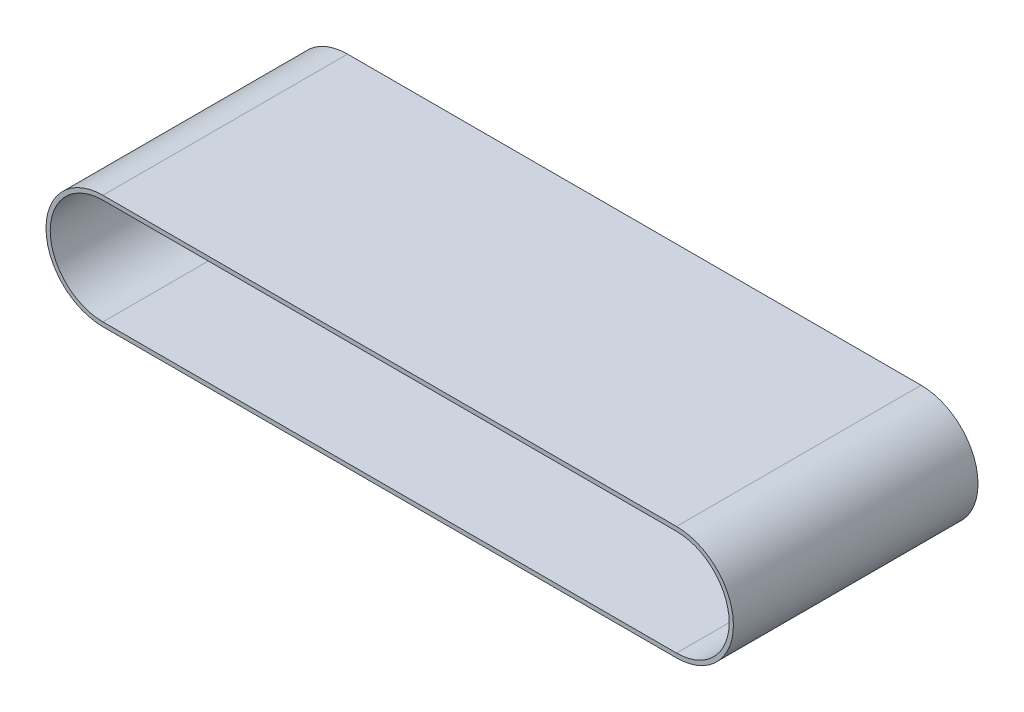
from build123d import *

# Parameters (mm, degrees)
BOSS_EXTRUDE1_DEPTH = 58


with BuildPart() as part:
    # Sketch1 → Boss-Extrude1 (new body)
    with BuildSketch(Plane.XY):
        with BuildLine():
            ThreePointArc((52.841370729, 12.137062925), (66.341370729, -1.362937075), (52.841370729, -14.862937075))
            Line((52.841370729, -14.862937075), (-83.158629271, -14.862937075))
            ThreePointArc((-83.158629271, -14.862937075), (-96.658629271, -1.362937075), (-83.158629271, 12.137062925))
            Line((-83.158629271, 12.137062925), (52.841370729, 12.137062925))
        make_face()
        with BuildLine():
            ThreePointArc((52.841370729, -13.862937075), (65.341370729, -1.362937075), (52.841370729, 11.137062925))
            Line((52.841370729, 11.137062925), (-83.158629271, 11.137062925))
            ThreePointArc((-83.158629271, 11.137062925), (-95.658629271, -1.362937075), (-83.158629271, -13.862937075))
            Line((-83.158629271, -13.862937075), (52.841370729, -13.862937075))
        make_face(mode=Mode.SUBTRACT)
    extrude(amount=BOSS_EXTRUDE1_DEPTH)


solid = part.part
